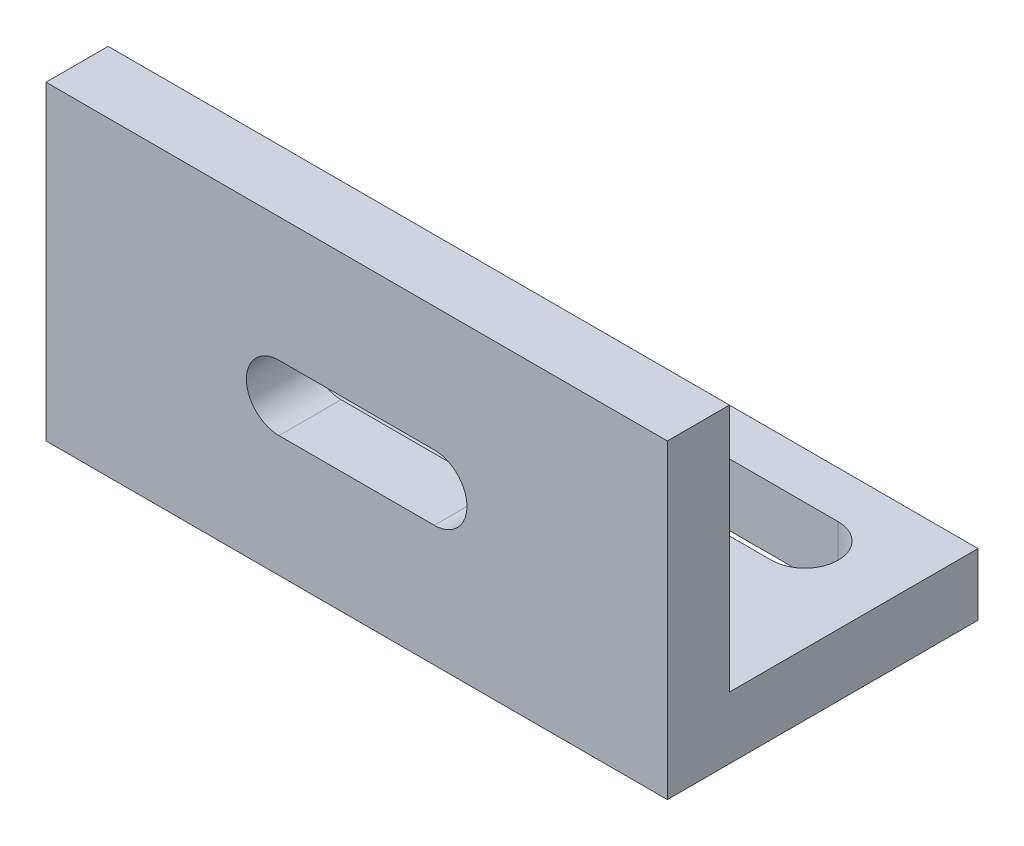
from build123d import *

# Parameters (mm, degrees)
SKETCH1_W           = 40
SKETCH1_H           = 20
BOSS_EXTRUDE1_DEPTH = 4
SKETCH5_W           = 40
SKETCH5_H           = 4
BOSS_EXTRUDE2_DEPTH = 16
CUT_EXTRUDE3_DEPTH  = 10
CUT_EXTRUDE5_DEPTH  = 10


with BuildPart() as part:
    # Sketch1 → Boss-Extrude1 (new body)
    with BuildSketch(Plane(origin=(0, 0, 0), x_dir=(1, 0, 0), z_dir=(0, 1, 0))):
        with Locations((-29.259259259, 2.888888889)):
            Rectangle(SKETCH1_W, SKETCH1_H)
    extrude(amount=BOSS_EXTRUDE1_DEPTH)

    # Sketch5 → Boss-Extrude2 (add)
    with BuildSketch(Plane(origin=(0, 4, 0), x_dir=(1, 0, 0), z_dir=(0, 1, 0))):
        with Locations((-29.259259259, -5.111111111)):
            Rectangle(SKETCH5_W, SKETCH5_H)
    extrude(amount=BOSS_EXTRUDE2_DEPTH)

    # Sketch7 → Cut-Extrude3 (cut)
    with BuildSketch(Plane(origin=(0, 4, 0), x_dir=(1, 0, 0), z_dir=(0, 1, 0))):
        with BuildLine():
            Line((-15.259259259, 5.588888889), (-43.259259259, 5.588888889))
            ThreePointArc((-43.259259259, 5.588888889), (-45.409259259, 7.738888889), (-43.259259259, 9.888888889))
            Line((-43.259259259, 9.888888889), (-15.259259259, 9.888888889))
            ThreePointArc((-15.259259259, 9.888888889), (-13.109259259, 7.738888889), (-15.259259259, 5.588888889))
        make_face()
    extrude(amount=-CUT_EXTRUDE3_DEPTH, mode=Mode.SUBTRACT)

    # Sketch8 → Cut-Extrude5 (cut)
    with BuildSketch(Plane(origin=(0, 0, 3.111111111), x_dir=(-1, 0, 0), z_dir=(0, 0, -1))):
        with BuildLine():
            Line((24.259259259, 11.997218425), (34.259259259, 11.997218425))
            ThreePointArc((34.259259259, 11.997218425), (36.359259259, 9.897218425), (34.259259259, 7.797218425))
            Line((34.259259259, 7.797218425), (24.259259259, 7.797218425))
            ThreePointArc((24.259259259, 7.797218425), (22.159259259, 9.897218425), (24.259259259, 11.997218425))
        make_face()
    extrude(amount=-CUT_EXTRUDE5_DEPTH, mode=Mode.SUBTRACT)


solid = part.part
